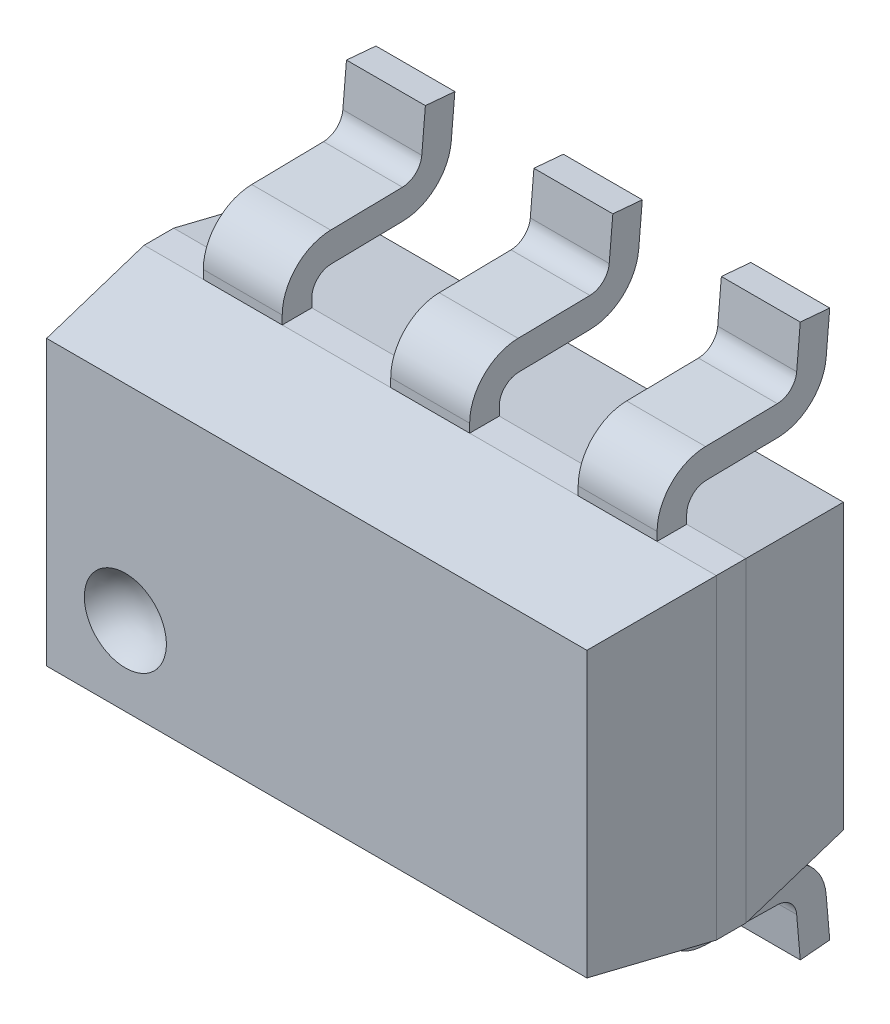
from build123d import *
from OCP.BRepFilletAPI import BRepFilletAPI_MakeChamfer
from build123d.topology import SkipClean

# Parameters (mm, degrees)
BODYWXH_W          = 1.3
BODYWXH_H          = 1.6
BOSS_BODY_DEPTH    = 1.45
CHAMFER1_SIZE      = 0.575
CHAMFER1_SIZE2     = 0.08081098
PINS_DEPTH         = 0.4
PATTERNLEADS_COUNT = 3
PATTERNLEADS_PITCH = 0.95


with BuildPart() as part:
    # BodyWxH → Boss-Body (new, symmetric)
    with BuildSketch(Plane(origin=(0, 0, 0), x_dir=(0, 0, -1), z_dir=(1, 0, 0))):
        with Locations((-0.8, 0)):
            Rectangle(BODYWXH_W, BODYWXH_H)
    extrude(amount=BOSS_BODY_DEPTH, both=True)

    # Chamfer1: one chamfer whose edges measure the first distance from different faces: ONE call of the kernel's chamfer builder (chamfer() names one face for all edges)
    chamfer1_edges_1 = [part.edges().sort_by_distance(p)[0] for p in [
        (0, -0.8, 0.15),
        (0, -0.8, 1.45),
    ]]
    chamfer1_side_1 = [part.faces().sort_by_distance(p)[0] for p in [
        (0, -0.8, 0.8),
    ]]
    chamfer1_edges_2 = [part.edges().sort_by_distance(p)[0] for p in [
        (1.45, 0, 0.15),
        (1.45, 0, 1.45),
    ]]
    chamfer1_side_2 = [part.faces().sort_by_distance(p)[0] for p in [
        (1.45, 0, 0.8),
    ]]
    chamfer1_edges_3 = [part.edges().sort_by_distance(p)[0] for p in [
        (0, 0.8, 0.15),
        (0, 0.8, 1.45),
    ]]
    chamfer1_side_3 = [part.faces().sort_by_distance(p)[0] for p in [
        (0, 0.8, 0.8),
    ]]
    chamfer1_edges_4 = [part.edges().sort_by_distance(p)[0] for p in [
        (-1.45, 0, 0.15),
        (-1.45, 0, 1.45),
    ]]
    chamfer1_side_4 = [part.faces().sort_by_distance(p)[0] for p in [
        (-1.45, 0, 0.8),
    ]]
    chamfer1 = BRepFilletAPI_MakeChamfer(part.part.solid().wrapped)
    for e in chamfer1_edges_1:
        chamfer1.Add(CHAMFER1_SIZE, CHAMFER1_SIZE2, e.wrapped, chamfer1_side_1[0].wrapped)  # the first distance lies on this face
    for e in chamfer1_edges_2:
        chamfer1.Add(CHAMFER1_SIZE, CHAMFER1_SIZE2, e.wrapped, chamfer1_side_2[0].wrapped)  # the first distance lies on this face
    for e in chamfer1_edges_3:
        chamfer1.Add(CHAMFER1_SIZE, CHAMFER1_SIZE2, e.wrapped, chamfer1_side_3[0].wrapped)  # the first distance lies on this face
    for e in chamfer1_edges_4:
        chamfer1.Add(CHAMFER1_SIZE, CHAMFER1_SIZE2, e.wrapped, chamfer1_side_4[0].wrapped)  # the first distance lies on this face
    add(Compound.cast(chamfer1.Shape()), mode=Mode.REPLACE)

    # LeadCross → Pins (add)
    with BuildSketch(Plane(origin=(-1.15, 0, 0), x_dir=(0, 0, -1), z_dir=(1, 0, 0))):
        with BuildLine():
            Line((0, -1.386926639), (-0.149429205, -1.4))
            Line((-0.149429205, -1.4), (-0.167692783, -1.19124635))
            ThreePointArc((-0.167692783, -1.19124635), (-0.199112416, -1.126826554), (-0.265567012, -1.099977154))
            Line((-0.265567012, -1.099977154), (-0.629363102, -1.09362707))
            ThreePointArc((-0.629363102, -1.09362707), (-0.803312612, -1.018892462), (-0.875, -0.843665146))
            Line((-0.875, -0.843665146), (-0.875, 0.843665146))
            ThreePointArc((-0.875, 0.843665146), (-0.803312612, 1.018892462), (-0.629363102, 1.09362707))
            Line((-0.629363102, 1.09362707), (-0.265567012, 1.099977154))
            ThreePointArc((-0.265567012, 1.099977154), (-0.199112416, 1.126826554), (-0.167692783, 1.19124635))
            Line((-0.167692783, 1.19124635), (-0.149429205, 1.4))
            Line((-0.149429205, 1.4), (0, 1.386926639))
            Line((0, 1.386926639), (-0.018263578, 1.178172988))
            ThreePointArc((-0.018263578, 1.178172988), (-0.096812662, 1.017123498), (-0.262949151, 0.95))
            Line((-0.262949151, 0.95), (-0.626745241, 0.943649916))
            ThreePointArc((-0.626745241, 0.943649916), (-0.696325045, 0.913756073), (-0.725, 0.843665146))
            Line((-0.725, 0.843665146), (-0.725, -0.843665146))
            ThreePointArc((-0.725, -0.843665146), (-0.696325045, -0.913756073), (-0.626745241, -0.943649916))
            Line((-0.626745241, -0.943649916), (-0.262949151, -0.95))
            ThreePointArc((-0.262949151, -0.95), (-0.096812662, -1.017123498), (-0.018263578, -1.178172988))
            Line((-0.018263578, -1.178172988), (0, -1.386926639))
        make_face()
    pins = extrude(amount=PINS_DEPTH)

    # PatternLeads: Pins ×3
    with Locations(*[(i * PATTERNLEADS_PITCH, 0, 0) for i in range(1, PATTERNLEADS_COUNT)]):
        add(pins)

    # Pin1Indent → Cut-Pin1Indent (revolve, cut)
    with SkipClean():  # the faces are left unmerged after this step: merging them gives an invalid solid
        with BuildSketch(Plane(origin=(-0.97, 0, 0), x_dir=(0, 0, -1), z_dir=(1, 0, 0))):
            with BuildLine():
                Line((-1.57, -0.08), (-1.57, -0.56))
                ThreePointArc((-1.57, -0.56), (-1.33, -0.32), (-1.57, -0.08))
            make_face()
        revolve(axis=Axis((-0.97, -0.08, 1.57), (0, -1, 0)), mode=Mode.SUBTRACT)


solid = part.part
